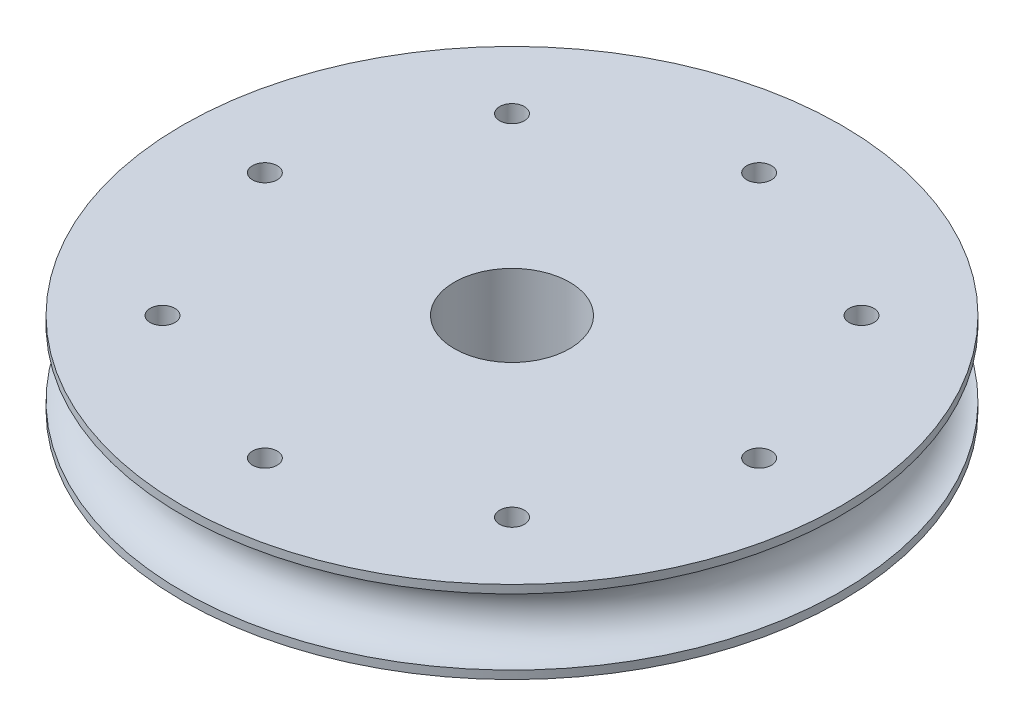
from build123d import *

# Parameters (mm, degrees)
SKETCH1_R           = 20
SKETCH1_R_2         = 3.5
BOSS_EXTRUDE1_DEPTH = 5
SKETCH3_R           = 0.75
CUT_EXTRUDE1_DEPTH  = 6


with BuildPart() as part:
    # Sketch1 → Boss-Extrude1 (new body)
    with BuildSketch(Plane(origin=(0, 0, 0), x_dir=(1, 0, 0), z_dir=(0, 1, 0))):
        Circle(SKETCH1_R)
        Circle(SKETCH1_R_2, mode=Mode.SUBTRACT)
    extrude(amount=BOSS_EXTRUDE1_DEPTH)

    # Sketch2 → Cut-Revolve1 (revolve, cut)
    with BuildSketch(Plane.XY):
        with BuildLine():
            Line((-20, 0.5), (-20, 4.5))
            ThreePointArc((-20, 4.5), (-18, 2.5), (-20, 0.5))
        make_face()
    revolve(axis=Axis((0, 0, 0), (0, 1, 0)), mode=Mode.SUBTRACT)

    # Sketch3 → Cut-Extrude1 (cut, through all)
    with BuildSketch(Plane(origin=(0, 0, 0), x_dir=(1, 0, 0), z_dir=(0, 1, 0))):
        with Locations((0, -15)):
            Circle(SKETCH3_R)
        with Locations((-10.606601718, -10.606601718)):
            Circle(SKETCH3_R)
        with Locations((-15, 0)):
            Circle(SKETCH3_R)
        with Locations((-10.606601718, 10.606601718)):
            Circle(SKETCH3_R)
        with Locations((0, 15)):
            Circle(SKETCH3_R)
        with Locations((10.606601718, 10.606601718)):
            Circle(SKETCH3_R)
        with Locations((15, 0)):
            Circle(SKETCH3_R)
        with Locations((10.606601718, -10.606601718)):
            Circle(SKETCH3_R)
    extrude(amount=CUT_EXTRUDE1_DEPTH, mode=Mode.SUBTRACT)


solid = part.part
